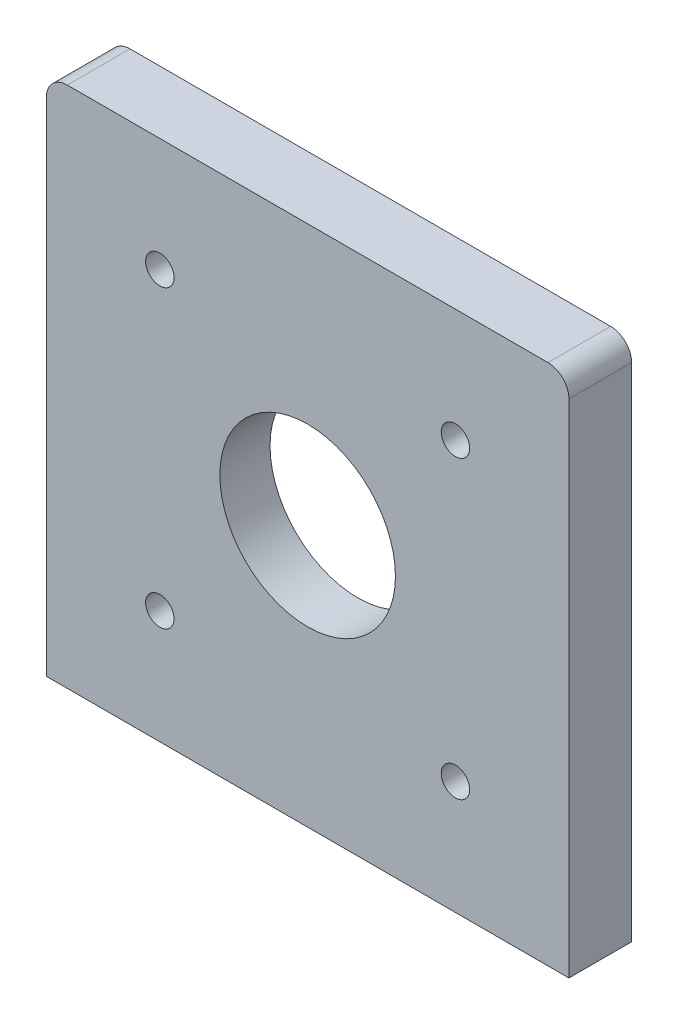
from build123d import *

# Parameters (mm, degrees)
ESQUISSE1_W             = 125
ESQUISSE1_H             = 125
BOSS_EXTRU_1_DEPTH      = 15
ESQUISSE2_R             = 40
ENL_V_MAT_EXTRU_1_DEPTH = 3
CONG_1_R                = 5
ESQUISSE11_R            = 21
ENL_V_MAT_EXTRU_2_DEPTH = 15
TROU_TARAUD_M81_D       = 6.8
TROU_TARAUD_M81_DEPTH   = 22.25
TROU_TARAUD_M81_TIP     = 2.042926105


with BuildPart() as part:
    # Esquisse1 → Boss.-Extru.1 (new body)
    with BuildSketch(Plane.XY):
        with Locations((-62.5, 62.5)):
            Rectangle(ESQUISSE1_W, ESQUISSE1_H)
    extrude(amount=BOSS_EXTRU_1_DEPTH)

    # Esquisse2 → Enlèv. mat.-Extru.1 (cut)
    with BuildSketch(Plane(origin=(0, 0, 0), x_dir=(-1, 0, 0), z_dir=(0, 0, -1))):
        with Locations((62.5, 62.5)):
            Circle(ESQUISSE2_R)
    extrude(amount=-ENL_V_MAT_EXTRU_1_DEPTH, mode=Mode.SUBTRACT)

    # Congé1
    cong_1_edges = [part.edges().sort_by_distance(p)[0] for p in [
        (-125, 125, 7.5),
        (0, 125, 7.5),
    ]]
    fillet(cong_1_edges, radius=CONG_1_R)

    # Esquisse11 → Enlèv. mat.-Extru.2 (cut)
    with BuildSketch(Plane(origin=(0, 0, 3), x_dir=(-1, 0, 0), z_dir=(0, 0, -1))):
        with Locations((62.5, 62.5)):
            Circle(ESQUISSE11_R)
    extrude(amount=-ENL_V_MAT_EXTRU_2_DEPTH, mode=Mode.SUBTRACT)

    # Trou taraudé M81
    with Locations(Plane(origin=(0, 0, 0), x_dir=(-1, 0, 0), z_dir=(0, 0, -1))):
        with Locations((97.855339059, 97.855339059), (27.144660941, 97.855339059), (27.144660941, 27.144660941), (97.855339059, 27.144660941)):
            Hole(TROU_TARAUD_M81_D / 2, depth=TROU_TARAUD_M81_DEPTH)
            with Locations((0, 0, -(TROU_TARAUD_M81_DEPTH + TROU_TARAUD_M81_TIP / 2))):  # 118° drill point
                Cone(0, TROU_TARAUD_M81_D / 2, TROU_TARAUD_M81_TIP, mode=Mode.SUBTRACT)


solid = part.part
